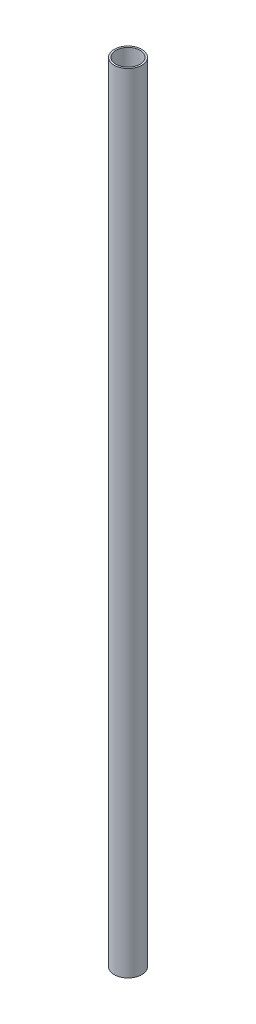
from build123d import *

# Parameters (mm, degrees)
SKETCH1_R      = 9.525
SKETCH1_R_2    = 8.325
EXTRUDE1_DEPTH = 543


with BuildPart() as part:
    # Sketch1 → Extrude1 (new body)
    with BuildSketch(Plane(origin=(0, -521.327437838, 0), x_dir=(1, 0, 0), z_dir=(0, 1, 0))):
        Circle(SKETCH1_R)
        Circle(SKETCH1_R_2, mode=Mode.SUBTRACT)
    extrude(amount=EXTRUDE1_DEPTH)


solid = part.part
